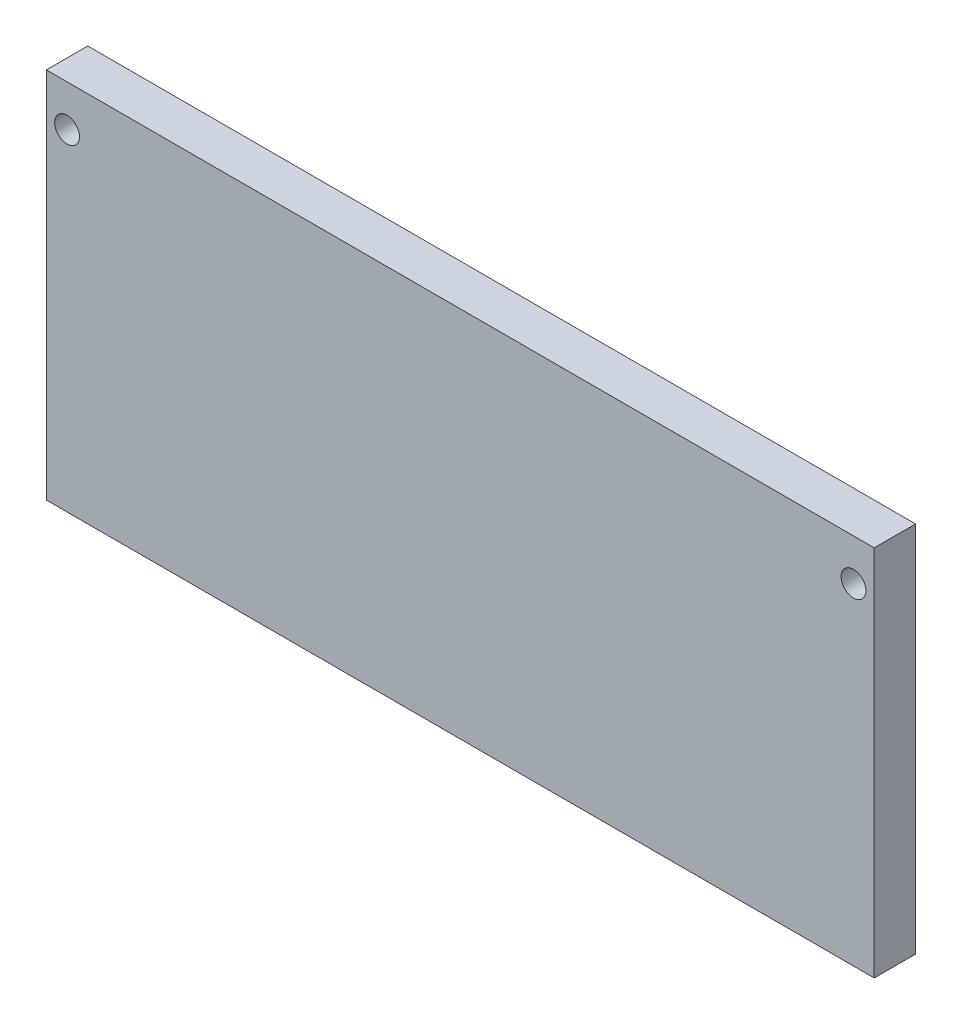
from build123d import *

# Parameters (mm, degrees)
SKETCH1_W           = 100
SKETCH1_H           = 45
SKETCH1_R           = 1.5
BOSS_EXTRUDE1_DEPTH = 5


with BuildPart() as part:
    # Sketch1 → Boss-Extrude1 (new body)
    with BuildSketch(Plane.XY):
        with Locations((50, 22.5)):
            Rectangle(SKETCH1_W, SKETCH1_H)
        with Locations((2.5, 40)):
            Circle(SKETCH1_R, mode=Mode.SUBTRACT)
        with Locations((97.5, 40)):
            Circle(SKETCH1_R, mode=Mode.SUBTRACT)
    extrude(amount=BOSS_EXTRUDE1_DEPTH)


solid = part.part
